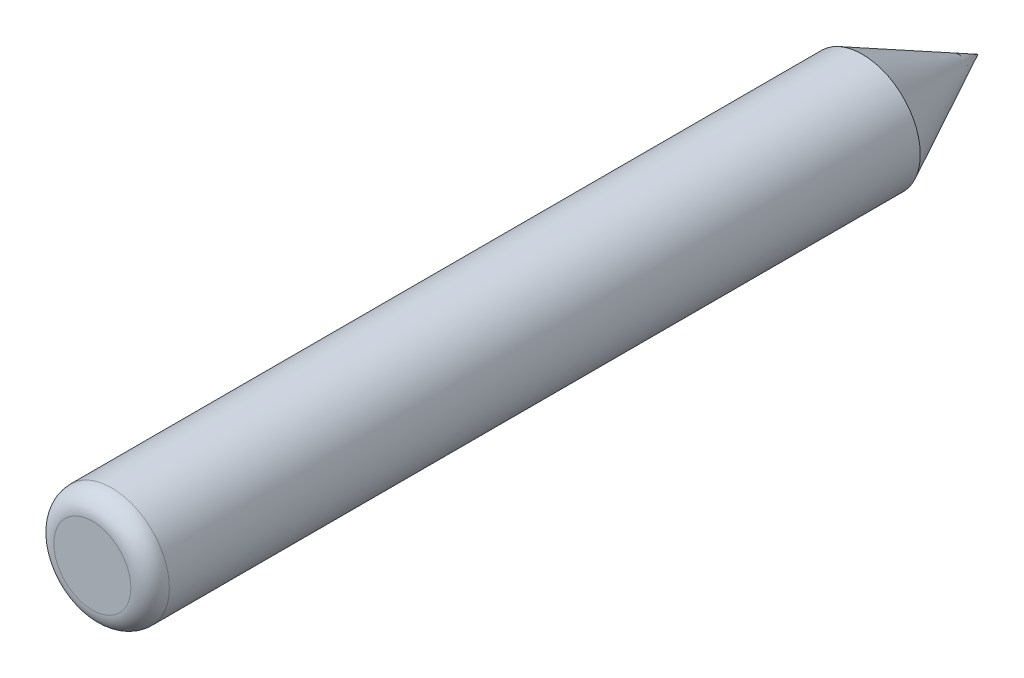
from build123d import *

# Parameters (mm, degrees)
ESQUISSE1_R        = 6
BOSS_EXTRU_1_DEPTH = 80
CONG_1_R           = 2


with BuildPart() as part:
    # Esquisse1 → Boss.-Extru.1 (new body)
    with BuildSketch(Plane.XY):
        Circle(ESQUISSE1_R)
    extrude(amount=BOSS_EXTRU_1_DEPTH)

    # Esquisse4 → Révolution1 (revolve)
    with BuildSketch(Plane(origin=(0, 0, 0), x_dir=(1, 0, 0), z_dir=(0, 1, 0))):
        Polygon((0, 0), (0, 12), (-6, 0), align=None)
    revolve(axis=Axis((0, 0, 0), (0, 0, -1)))

    # Congé1
    cong_1_edges = [part.edges().sort_by_distance(p)[0] for p in [
        (-6, 0, 80),
    ]]
    fillet(cong_1_edges, radius=CONG_1_R)


solid = part.part
